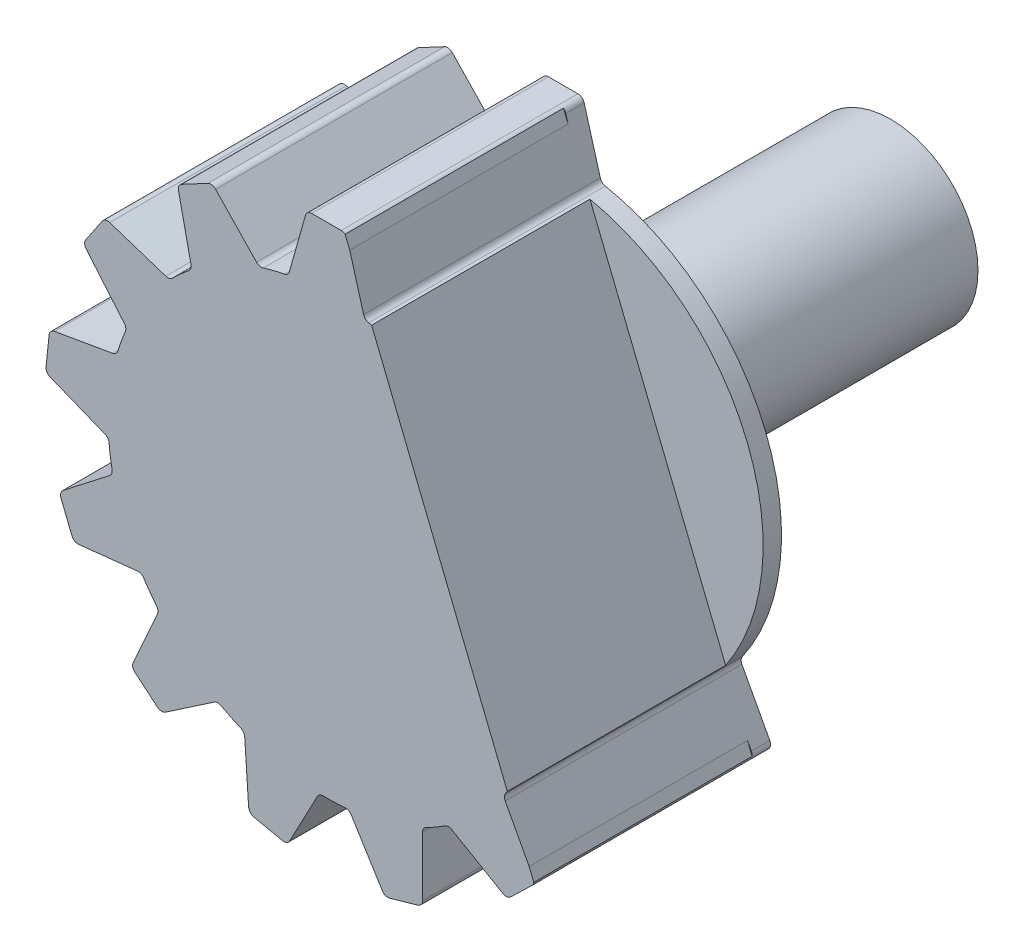
from build123d import *

# Parameters (mm, degrees)
ESQUISSE1_R                        = 10
MAIN_EXTRUSION_DEPTH               = 10.841776527
GEAR_ELEMENT_DEPTH                 = 10.841776527
CONG_1_R                           = 0.3
R_P_TITION_CIRCULAIRE1_COUNT       = 9
R_P_TITION_CIRCULAIRE1_ANGLE       = 224
CONG_1_OF_R_P_TITION_CIRCULAIRE1_R = 0.3
ESQUISSE3_R                        = 4
MAIN_AXE_DEPTH                     = 15
ESQUISSE4_W                        = 5
ESQUISSE4_H                        = 1
AXE_TRAIT_DEPTH                    = 3
ENL_V_MAT_EXTRU_1_DEPTH            = 10


with BuildPart() as part:
    # Esquisse1 → Main Extrusion (new body)
    with BuildSketch(Plane.XY):
        Circle(ESQUISSE1_R)
    extrude(amount=MAIN_EXTRUSION_DEPTH)

    # Esquisse2 → Gear Element (add)
    with BuildSketch(Plane.XY.offset(10.841776527)):
        Polygon((-1.75, 9.845684334), (1.75, 9.845684334), (0.9, 12.845684334), (-0.9, 12.845684334), align=None)
    gear_element = extrude(amount=-GEAR_ELEMENT_DEPTH)

    # Congé1
    cong_1_edges = [part.edges().sort_by_distance(p)[0] for p in [
        (-1.75, 9.845684334, 5.420888263),
        (-0.9, 12.845684334, 5.420888263),
        (0.9, 12.845684334, 5.420888263),
        (1.75, 9.845684334, 5.420888263),
    ]]
    fillet(cong_1_edges, radius=CONG_1_R)

    # Répétition circulaire1: Gear Element ×9 about axis
    r_p_tition_circulaire1_axis = Axis((0, 0, 0), (0, 0, 1))
    for i in range(1, R_P_TITION_CIRCULAIRE1_COUNT):
        add(gear_element.rotate(r_p_tition_circulaire1_axis, i * R_P_TITION_CIRCULAIRE1_ANGLE / (R_P_TITION_CIRCULAIRE1_COUNT - 1)))

    # Congé1 of Répétition circulaire1
    cong_1_of_r_p_tition_circulaire1_edges = [part.edges().sort_by_distance(p)[0] for p in [
        (-6.167427098, 7.871648048, 5.420888263),
        (-6.825336333, 10.919541655, 5.420888263),
        (-5.236030666, 11.764590468, 5.420888263),
        (-3.077110523, 9.514798517, 5.420888263),
        (-9.141029821, 4.054821057, 5.420888263),
        (-11.152828571, 6.437081704, 5.420888263),
        (-10.146281345, 7.929349335, 5.420888263),
        (-7.183854659, 6.956452561, 5.420888263),
        (-9.974673456, -0.711259064, 5.420888263),
        (-12.869389948, 0.447669937, 5.420888263),
        (-12.681238714, 2.237809349, 5.420888263),
        (-9.608823834, 2.76956757, 5.420888263),
        (-8.473198013, -5.310830014, 5.420888263),
        (-11.573165181, -5.646543517, 5.420888263),
        (-12.247457049, -3.977612579, 5.420888263),
        (-9.78432109, -2.065686523, 5.420888263),
        (-4.988106123, -8.66711009, 5.420888263),
        (-7.567606729, -10.418873951, 5.420888263),
        (-8.946486726, -9.261856253, 5.420888263),
        (-7.669261674, -6.417353456, 5.420888263),
        (-0.335274576, -9.994377968, 5.420888263),
        (-1.790435109, -12.752095833, 5.420888263),
        (-3.55110079, -12.377854789, 5.420888263),
        (-3.758791178, -9.26668705, 5.420888263),
        (4.396046364, -8.981913848, 5.420888263),
        (4.40588599, -12.099990688, 5.420888263),
        (2.675614937, -12.596137928, 5.420888263),
        (1.031630428, -9.946644593, 5.420888263),
        (8.098231686, -5.866740455, 5.420888263),
        (9.570767967, -8.61521947, 5.420888263),
        (8.275956326, -9.865604537, 5.420888263),
        (5.580542385, -8.298044751, 5.420888263),
    ]]
    fillet(cong_1_of_r_p_tition_circulaire1_edges, radius=CONG_1_OF_R_P_TITION_CIRCULAIRE1_R)

    # Esquisse3 → Main Axe (add)
    with BuildSketch(Plane(origin=(0, 0, 0), x_dir=(-1, 0, 0), z_dir=(0, 0, -1))):
        with Locations(Location((0, 0, 0), (0, 0, 180))):
            Circle(ESQUISSE3_R)
    extrude(amount=MAIN_AXE_DEPTH)

    # Esquisse4 → Axe Trait (cut)
    with BuildSketch(Plane(origin=(0, 0, -15), x_dir=(-1, 0, 0), z_dir=(0, 0, -1))):
        Rectangle(ESQUISSE4_W, ESQUISSE4_H)
    extrude(amount=-AXE_TRAIT_DEPTH, mode=Mode.SUBTRACT)

    # Esquisse5 → Enlèv. mat.-Extru.1 (cut)
    with BuildSketch(Plane.XY.offset(10.841776527)):
        Polygon((0.854113079, 12.78498982), (9.495597726, -8.603435225), (13.592580869, -6.948146588), (4.951096222, 14.440278457), align=None)
    extrude(amount=-ENL_V_MAT_EXTRU_1_DEPTH, mode=Mode.SUBTRACT)


solid = part.part
